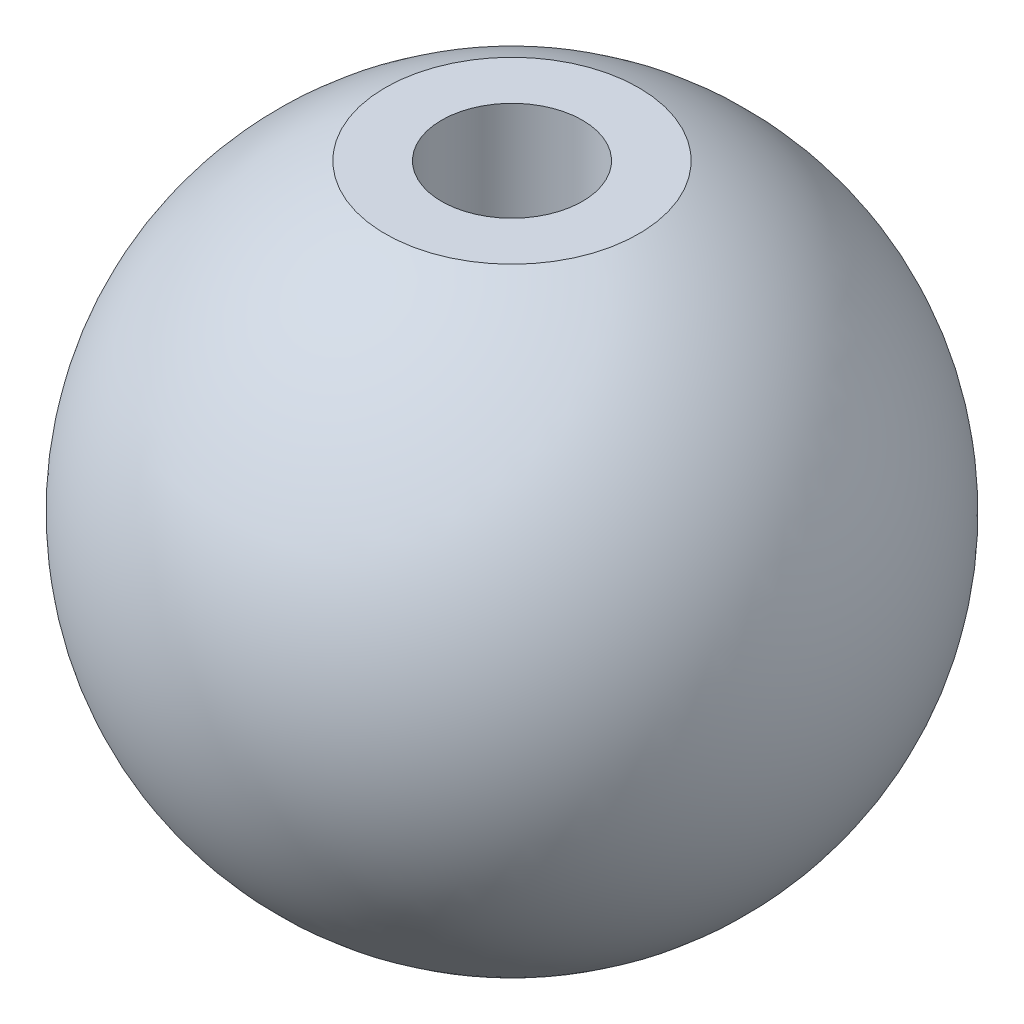
from build123d import *

# Parameters (mm, degrees)
SKETCH2_R               = 2.5
CUT_EXTRUDE1_DEPTH      = 12.105084746
CUT_EXTRUDE1_DEPTH_BACK = 13.294915254
CUT_EXTRUDE2_DEPTH      = 12.7
CUT_EXTRUDE2_DEPTH_BACK = 12.7


with BuildPart() as part:
    # Sketch1 → Revolve1 (revolve)
    with BuildSketch(Plane.XY):
        with BuildLine():
            Line((0, 11.105084746), (0, -12.294915254))
            ThreePointArc((0, -12.294915254), (-11.7, -0.594915254), (0, 11.105084746))
        make_face()
    revolve(axis=Axis((0, 11.105084746, 0), (0, -1, 0)))

    # Sketch2 → Cut-Extrude1 (cut, two sides)
    with BuildSketch(Plane(origin=(0, 0, 0), x_dir=(1, 0, 0), z_dir=(0, 1, 0))) as cut_extrude1_sk:
        Circle(SKETCH2_R)
    extrude(amount=CUT_EXTRUDE1_DEPTH, mode=Mode.SUBTRACT)
    extrude(cut_extrude1_sk.sketch, amount=-CUT_EXTRUDE1_DEPTH_BACK, mode=Mode.SUBTRACT)

    # Sketch6 → Cut-Extrude2 (cut, two sides)
    with BuildSketch(Plane.XY) as cut_extrude2_sk:
        Polygon((0, 12.205084746), (-13.76858677, 12.205084746), (-13.76858677, 10.205084746), (12.631256699, 10.205084746), (12.631256699, 12.205084746), align=None)
        Polygon((0, -13.394915254), (12.631256699, -13.394915254), (12.631256699, -11.394915254), (-13.76858677, -11.394915254), (-13.76858677, -13.394915254), align=None)
    extrude(amount=CUT_EXTRUDE2_DEPTH, mode=Mode.SUBTRACT)
    extrude(cut_extrude2_sk.sketch, amount=-CUT_EXTRUDE2_DEPTH_BACK, mode=Mode.SUBTRACT)


solid = part.part
